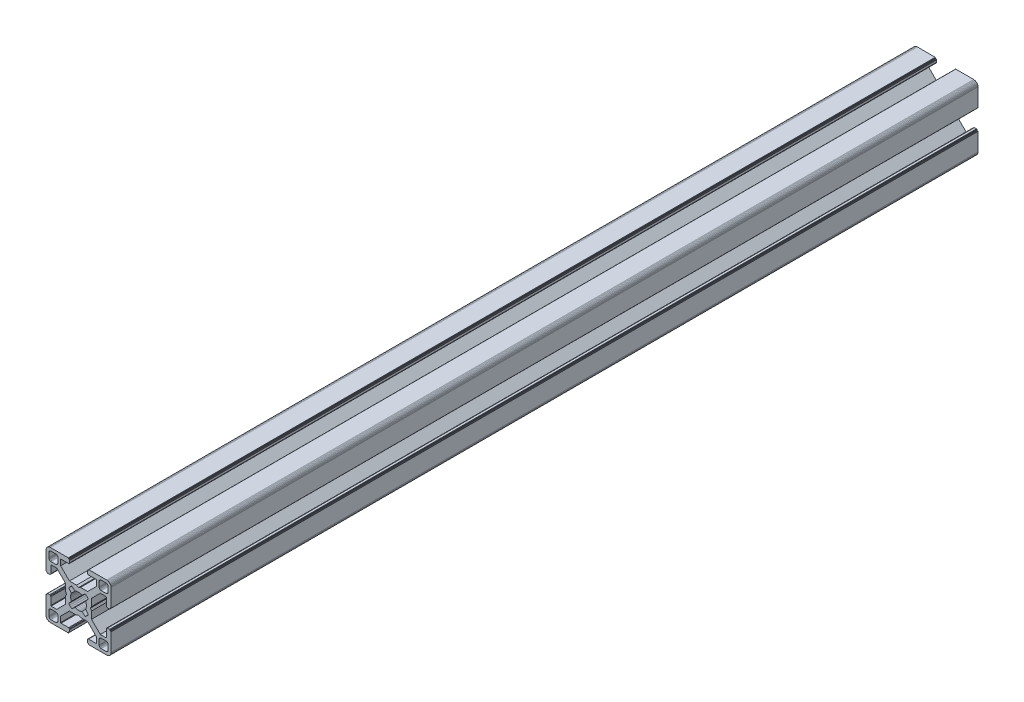
from build123d import *

# Parameters (mm, degrees)
BOSS_EXTRUDE1_DEPTH = 400


with BuildPart() as part:
    # Sketch1 → Boss-Extrude1 (new body)
    with BuildSketch(Plane.XY):
        Polygon((28.34729664, 29.969613999), (28.000000864, 29.999999329), (19.750000909, 29.999999329), (19.715268165, 29.996961355), (19.681595266, 29.987938702), (19.649999216, 29.973205179), (19.621443003, 29.953207821), (19.596790895, 29.928557575), (19.576793537, 29.899999499), (19.562061876, 29.868405312), (19.55303736, 29.834728688), (19.549999386, 29.799999669), (19.549999386, 29.699999839), (19.546961412, 29.665268958), (19.537936896, 29.631596059), (19.523203373, 29.599998146), (19.503207877, 29.571441934), (19.478557631, 29.546789825), (19.449999556, 29.526794329), (19.418403506, 29.512060806), (19.384728745, 29.503038153), (19.349999726, 29.500000179), (19.249999896, 29.500000179), (19.215267517, 29.496958527), (19.181592755, 29.487935874), (19.149996706, 29.47320235), (19.12143863, 29.453206855), (19.096788384, 29.428554746), (19.076791026, 29.399996671), (19.062057503, 29.368402484), (19.05303485, 29.334725859), (19.049996876, 29.299998703), (19.049996876, 28.39999837), (19.059110798, 28.29580945), (19.08618062, 28.194785165), (19.13038119, 28.099997016), (19.190369539, 28.014324653), (19.264324002, 27.94037019), (19.349996366, 27.88038184), (19.444784515, 27.836181271), (19.545806937, 27.809111449), (19.650010894, 27.799984574), (23.050010706, 27.799984574), (23.084741588, 27.7969466), (23.118414487, 27.787923946), (23.150012399, 27.773190423), (23.178568612, 27.753193065), (23.203220721, 27.728542819), (23.223218079, 27.699984744), (23.237949739, 27.668386831), (23.246974255, 27.634713932), (23.25001142, 27.59998608), (23.25001142, 25.049987618), (19.204474482, 20.999982084), (15.900007876, 20.999982084), (15.000008474, 20.48483404), (14.10000814, 20.999982084), (10.795543398, 20.999982084), (7.997342887, 23.801274731), (6.750011387, 25.049984589), (6.750011387, 27.599983051), (6.753049362, 27.634713932), (6.762072946, 27.668386831), (6.776805538, 27.699984744), (6.796801965, 27.728542819), (6.821454073, 27.753193065), (6.850011218, 27.773190423), (6.881607267, 27.787923946), (6.915282029, 27.7969466), (6.950011048, 27.799984574), (10.350011791, 27.799984574), (10.45420071, 27.809098497), (10.555223133, 27.836168318), (10.650011282, 27.880368888), (10.735683645, 27.940357238), (10.809638108, 28.014311701), (10.869626458, 28.099984064), (10.913827027, 28.194772213), (10.940895918, 28.295796498), (10.950010772, 28.399985417), (10.950010772, 29.299985751), (10.946974575, 29.334739239), (10.93795065, 29.368415522), (10.923215933, 29.400009153), (10.903218427, 29.428566473), (10.878566319, 29.45321765), (10.849999264, 29.473204166), (10.818403214, 29.487937689), (10.784728453, 29.496960342), (10.749999434, 29.500000179), (10.649999604, 29.500000179), (10.615270585, 29.503038153), (10.581595823, 29.512060806), (10.549999774, 29.526794329), (10.521441698, 29.546789825), (10.496791452, 29.571441934), (10.476795025, 29.599998146), (10.462061502, 29.631596059), (10.453037918, 29.665268958), (10.449999943, 29.699999839), (10.449999943, 29.799999669), (10.446961969, 29.834728688), (10.437938385, 29.868405312), (10.423205793, 29.899999499), (10.403208435, 29.928557575), (10.378557257, 29.953207821), (10.350000113, 29.973205179), (10.318404064, 29.987938702), (10.284729302, 29.996961355), (10.250000283, 29.999999329), (1.999999397, 29.999999329), (1.652702689, 29.969613999), (1.315958682, 29.879383743), (0.999999233, 29.732050374), (0.714424066, 29.532089829), (0.467910431, 29.285576195), (0.267948955, 28.999999166), (0.120614655, 28.684040532), (0.030384399, 28.34729664), (0, 28.000000864), (0, 19.750000909), (0.003037974, 19.715268165), (0.012061559, 19.681595266), (0.026795082, 19.649999216), (0.046790577, 19.621441141), (0.071442686, 19.596789032), (0.09999983, 19.576793537), (0.13159588, 19.562060013), (0.165270641, 19.55303736), (0.19999966, 19.549999386), (0.299999461, 19.549999386), (0.334728509, 19.546959549), (0.368403242, 19.537936896), (0.399999321, 19.523203373), (0.428556465, 19.503207877), (0.453208573, 19.478555769), (0.473204069, 19.449997693), (0.487937592, 19.418403506), (0.496961176, 19.384728745), (0.499999151, 19.349999726), (0.499999151, 19.249998033), (0.503038056, 19.215269014), (0.512060709, 19.181594253), (0.526794232, 19.150000066), (0.546790194, 19.121441524), (0.571441837, 19.096789882), (0.60000029, 19.076794925), (0.631595686, 19.062061999), (0.665270619, 19.053039982), (0.700000626, 19.050000801), (1.60000096, 19.050000801), (1.704189879, 19.059116587), (1.805213233, 19.086186409), (1.90000045, 19.130385115), (1.985673745, 19.190375328), (2.059627277, 19.264327928), (2.119616325, 19.350002154), (2.163816196, 19.444788441), (2.190886018, 19.545812726), (2.200000872, 19.650001645), (2.200000872, 23.050001457), (2.203039777, 23.084732338), (2.212062431, 23.118405237), (2.226795954, 23.15000315), (2.246792381, 23.178559362), (2.271443558, 23.203211471), (2.300000702, 23.223206967), (2.331596752, 23.23794049), (2.365271513, 23.246965006), (2.400001464, 23.250001117), (4.950000857, 23.250001117), (7.997332093, 20.202670812), (8.995535423, 19.204467788), (8.995535423, 15.900001182), (9.515148227, 15.00000178), (8.995535423, 14.100002378), (8.995535423, 10.795536704), (4.950000857, 6.750002138), (2.400001464, 6.750002138), (2.365271513, 6.753040112), (2.331596752, 6.762063697), (2.300000702, 6.77679722), (2.271443558, 6.796793647), (2.246792381, 6.821444824), (2.226795954, 6.850001968), (2.212062431, 6.881598018), (2.203039777, 6.915272779), (2.200000872, 6.950002729), (2.200000872, 10.350002542), (2.190896812, 10.454174265), (2.16382699, 10.555197618), (2.119627119, 10.649984836), (2.059638071, 10.735658131), (1.985684539, 10.809611663), (1.900011244, 10.869600944), (1.805224027, 10.913800582), (1.704200673, 10.940870404), (1.600011754, 10.949986189), (0.70001142, 10.949986189), (0.665281355, 10.946948596), (0.631606253, 10.937926283), (0.600010578, 10.923193954), (0.571451747, 10.903199537), (0.546799638, 10.87854836), (0.526794232, 10.850000195), (0.512060709, 10.818404146), (0.503038056, 10.784730315), (0.499999151, 10.750000365), (0.499999151, 10.650000535), (0.496961176, 10.615270585), (0.487937592, 10.581596754), (0.473204069, 10.550000705), (0.453208573, 10.521443561), (0.428556465, 10.496791452), (0.399999321, 10.476795956), (0.368403242, 10.462062433), (0.334728509, 10.453038849), (0.299999461, 10.449999943), (0.19999966, 10.449999943), (0.165270641, 10.446961969), (0.13159588, 10.437939316), (0.09999983, 10.423205793), (0.071442686, 10.403209366), (0.046790577, 10.378558189), (0.026795082, 10.350000113), (0.012061559, 10.318404064), (0.003037974, 10.284729302), (0, 10.250000283), (0, 1.999999397), (0.030384399, 1.652702689), (0.120614655, 1.315958682), (0.267948955, 0.999999233), (0.467910431, 0.714424066), (0.714424066, 0.467910431), (0.999999233, 0.267948955), (1.315958682, 0.120614655), (1.652702689, 0.030384399), (1.999999397, 0), (10.250000283, 0), (10.284729302, 0.003037974), (10.318404064, 0.012061559), (10.350000113, 0.026795082), (10.378557257, 0.046790577), (10.403208435, 0.071442686), (10.423205793, 0.09999983), (10.437938385, 0.13159588), (10.446961969, 0.165270641), (10.449999943, 0.19999966), (10.449999943, 0.300000422), (10.453037918, 0.334729441), (10.462061502, 0.368404202), (10.476795025, 0.400000252), (10.496791452, 0.428557396), (10.521441698, 0.453208573), (10.549999774, 0.473205), (10.581595823, 0.487938523), (10.615270585, 0.496961176), (10.649999604, 0.500000082), (10.749999434, 0.500000082), (10.784728453, 0.503038056), (10.818403214, 0.512060709), (10.849999264, 0.526794232), (10.878547894, 0.546800104), (10.903198606, 0.571451747), (10.923194493, 0.6000102), (10.93792742, 0.631606528), (10.946949437, 0.66528146), (10.950010772, 0.699984975), (10.950010772, 1.599985308), (10.940895918, 1.704174228), (10.913827027, 1.805197581), (10.869626458, 1.89998573), (10.809638108, 1.985658094), (10.735683645, 2.059612557), (10.650011282, 2.119600674), (10.555223133, 2.163801476), (10.45420071, 2.190870367), (10.350011791, 2.199985221), (6.950011048, 2.199985221), (6.915282029, 2.203024126), (6.881607267, 2.212046779), (6.850011218, 2.226780302), (6.821454073, 2.246776729), (6.796801965, 2.271427907), (6.776805538, 2.299985982), (6.762072946, 2.331582032), (6.753049362, 2.365256793), (6.750011387, 2.399985812), (6.750011387, 4.949985206), (9.787457566, 7.990785077), (10.795545277, 8.999985833), (14.100010019, 8.999985833), (15.000010353, 9.515133877), (15.900009756, 8.999985833), (19.204476361, 8.999985833), (20.21256413, 7.990786065), (23.25001142, 4.949988235), (23.25001142, 2.399988841), (23.246974255, 2.365256793), (23.237949739, 2.331582032), (23.223218079, 2.299985982), (23.203220721, 2.271427907), (23.178568612, 2.246776729), (23.150012399, 2.226780302), (23.118414487, 2.212046779), (23.084741588, 2.203024126), (23.050010706, 2.199985221), (19.650010894, 2.199985221), (19.545806937, 2.190883319), (19.444784515, 2.163814428), (19.349996366, 2.119613626), (19.264324002, 2.059625509), (19.190369539, 1.985671046), (19.13038119, 1.899998682), (19.08618062, 1.805210533), (19.059110798, 1.70418718), (19.049996876, 1.599998261), (19.049996876, 0.699997927), (19.053035506, 0.665268966), (19.062058795, 0.631594374), (19.076792915, 0.599998603), (19.096790813, 0.571440905), (19.121441524, 0.546790194), (19.149999978, 0.526794306), (19.181596306, 0.51206138), (19.215271238, 0.503039363), (19.249999896, 0.500000082), (19.349999726, 0.500000082), (19.384728745, 0.496961176), (19.418403506, 0.487938523), (19.449999556, 0.473205), (19.478557631, 0.453208573), (19.503207877, 0.428557396), (19.523203373, 0.400000252), (19.537936896, 0.368404202), (19.546961412, 0.334729441), (19.549999386, 0.300000422), (19.549999386, 0.19999966), (19.55303736, 0.165270641), (19.562061876, 0.13159588), (19.576793537, 0.09999983), (19.596789964, 0.071441755), (19.621442072, 0.046789646), (19.649998285, 0.02679415), (19.681594335, 0.012060627), (19.715267234, 0.003037043), (19.750000909, 0), (28.000000864, 0), (28.34729664, 0.030384399), (28.684040532, 0.120614655), (28.999999166, 0.267948955), (29.285576195, 0.467910431), (29.532089829, 0.714424066), (29.732050374, 0.999999233), (29.879383743, 1.315958682), (29.969613999, 1.652702689), (29.999999329, 1.999999397), (29.999999329, 10.250000283), (29.996974806, 10.284715361), (29.987951516, 10.318389952), (29.973217396, 10.349985723), (29.953219499, 10.378543421), (29.928568787, 10.403194133), (29.899999499, 10.423205793), (29.868405312, 10.437939316), (29.834728688, 10.446961969), (29.799999669, 10.449999943), (29.699999839, 10.449999943), (29.664909937, 10.453400043), (29.631233313, 10.462423628), (29.599637263, 10.477157151), (29.57108105, 10.497152646), (29.546427079, 10.521804755), (29.526433446, 10.550361899), (29.511699923, 10.581957949), (29.502675407, 10.615631779), (29.499637433, 10.650361729), (29.499637433, 10.750361559), (29.49697202, 10.784715548), (29.487949367, 10.818389378), (29.473215844, 10.849985428), (29.453220348, 10.878542572), (29.428568239, 10.90319468), (29.400010164, 10.923190176), (29.368415977, 10.937923699), (29.334741215, 10.946947284), (29.300012197, 10.949986189), (28.400011863, 10.949986189), (28.29581215, 10.9408876), (28.194787865, 10.913817778), (28.099999716, 10.86961814), (28.014327352, 10.809628859), (27.940374752, 10.735675327), (27.880384539, 10.650002032), (27.836185833, 10.555214814), (27.809114148, 10.454191461), (27.800000225, 10.350002542), (27.800000225, 6.950002729), (27.796962251, 6.915272779), (27.787939598, 6.881598018), (27.773206075, 6.850001968), (27.753208716, 6.821444824), (27.728558471, 6.796793647), (27.700000395, 6.77679722), (27.668404345, 6.762063697), (27.634729584, 6.753040112), (27.599998702, 6.750002138), (25.05000024, 6.750002138), (23.809199132, 7.99080223), (21.004464477, 10.795534588), (21.004464477, 14.100000262), (20.484851673, 14.999999665), (21.004464477, 15.899999067), (21.004464477, 19.204465672), (25.05000024, 23.250001117), (27.599998702, 23.250001117), (27.634729584, 23.246965006), (27.668404345, 23.23794049), (27.700000395, 23.223206967), (27.728558471, 23.203211471), (27.753208716, 23.178559362), (27.773206075, 23.15000315), (27.787939598, 23.118405237), (27.796962251, 23.084732338), (27.800000225, 23.050001457), (27.800000225, 19.650001645), (27.809114148, 19.545812726), (27.836185833, 19.444788441), (27.880384539, 19.350002154), (27.940370508, 19.264323684), (28.014323108, 19.190371084), (28.099995472, 19.130380872), (28.194783621, 19.086182165), (28.295807906, 19.059112343), (28.400001069, 19.050000801), (29.300001402, 19.050000801), (29.334730421, 19.053040638), (29.368405183, 19.062063291), (29.39999937, 19.076796814), (29.42819671, 19.097149726), (29.452848353, 19.1218023), (29.472843309, 19.150360754), (29.487576235, 19.181955219), (29.496598252, 19.215630151), (29.499637433, 19.250359227), (29.499637433, 19.35036092), (29.502675407, 19.385089939), (29.511699923, 19.4187647), (29.526433446, 19.450358887), (29.546427079, 19.478916963), (29.57108105, 19.503569071), (29.599637263, 19.523564567), (29.631233313, 19.53829809), (29.664909937, 19.547320743), (29.699999839, 19.549999386), (29.799999669, 19.549999386), (29.834728688, 19.55303736), (29.868405312, 19.562060013), (29.899999499, 19.576793537), (29.928557575, 19.596789032), (29.953207821, 19.621441141), (29.973205179, 19.649999216), (29.987938702, 19.681595266), (29.996961355, 19.715268165), (29.999999329, 19.750000909), (29.999999329, 28.000000864), (29.969613999, 28.34729664), (29.879383743, 28.684040532), (29.732050374, 28.999999166), (29.532089829, 29.285576195), (29.285576195, 29.532089829), (28.999999166, 29.732050374), (28.684040532, 29.879383743), align=None)
        Polygon((1.299998723, 25.499999523), (1.299998723, 27.699999511), (1.312309876, 27.856435627), (1.348942518, 28.009016067), (1.408992335, 28.153989464), (1.490981318, 28.287785128), (1.592892222, 28.407108039), (1.71221327, 28.50901708), (1.846008119, 28.591006994), (1.9909814, 28.651056811), (2.143563703, 28.687689453), (2.299998887, 28.699999675), (4.499998875, 28.699999675), (4.656434059, 28.687689453), (4.809016362, 28.651056811), (4.953989759, 28.591006994), (5.087784491, 28.50901708), (5.207106471, 28.407108039), (5.309016444, 28.287785128), (5.391005427, 28.153989464), (5.451056175, 28.009016067), (5.487687886, 27.856435627), (5.499999039, 27.699999511), (5.499999039, 25.499999523), (5.487687886, 25.34356527), (5.451056175, 25.190982968), (5.391005427, 25.04600957), (5.309016444, 24.912213907), (5.207106471, 24.792892858), (5.087784491, 24.690981954), (4.953989759, 24.60899204), (4.809016362, 24.548944086), (4.656434059, 24.512309581), (4.499998875, 24.499999359), (2.299998887, 24.499999359), (2.143563703, 24.512309581), (1.9909814, 24.548944086), (1.846008119, 24.60899204), (1.71221327, 24.690981954), (1.592892222, 24.792892858), (1.490981318, 24.912213907), (1.408992335, 25.04600957), (1.348942518, 25.190982968), (1.312309876, 25.34356527), align=None, mode=Mode.SUBTRACT)
        Polygon((25.34356527, 28.687689453), (25.499999523, 28.699999675), (27.699999511, 28.699999675), (27.856435627, 28.687689453), (28.009017929, 28.651056811), (28.153991327, 28.591006994), (28.28778699, 28.50901708), (28.407108039, 28.407108039), (28.50901708, 28.287785128), (28.591006994, 28.153989464), (28.651056811, 28.009016067), (28.687689453, 27.856435627), (28.700001538, 27.699999511), (28.700001538, 25.499999523), (28.687689453, 25.34356527), (28.651056811, 25.190982968), (28.591006994, 25.04600957), (28.50901708, 24.912213907), (28.407108039, 24.792892858), (28.28778699, 24.690981954), (28.153991327, 24.60899204), (28.009017929, 24.548944086), (27.856435627, 24.512309581), (27.699999511, 24.499999359), (25.499999523, 24.499999359), (25.34356527, 24.512309581), (25.190982968, 24.548944086), (25.04600957, 24.60899204), (24.912215769, 24.690981954), (24.792892858, 24.792892858), (24.690981954, 24.912213907), (24.608993903, 25.04600957), (24.548944086, 25.190982968), (24.512311444, 25.34356527), (24.500001222, 25.499999523), (24.500001222, 27.699999511), (24.512311444, 27.856435627), (24.548944086, 28.009016067), (24.608993903, 28.153989464), (24.690981954, 28.287785128), (24.792892858, 28.407108039), (24.912215769, 28.50901708), (25.04600957, 28.591006994), (25.190982968, 28.651056811), align=None, mode=Mode.SUBTRACT)
        Polygon((14.999999665, 18.649999052), (15.550030395, 18.608318642), (16.087498516, 18.484227359), (16.600128263, 18.280562013), (18.13592948, 19.518401474), (18.644984812, 19.11874488), (19.103571773, 18.662061542), (19.505336881, 18.154669553), (18.280562013, 16.600130126), (18.484227359, 16.087498516), (18.608318642, 15.550030395), (18.649999052, 14.999999665), (18.608318642, 14.449968934), (18.484227359, 13.912500814), (18.280562013, 13.399870135), (19.505336881, 11.845329776), (19.103571773, 11.337937787), (18.644984812, 10.881252587), (18.13592948, 10.481598787), (16.600128263, 11.719437316), (16.087498516, 11.515771039), (15.550030395, 11.391680688), (14.999999665, 11.349999346), (14.449968934, 11.391680688), (13.912500814, 11.515771039), (13.399870135, 11.719437316), (11.864069849, 10.481598787), (11.355013587, 10.881252587), (10.896427557, 11.337937787), (10.494662449, 11.845329776), (11.719438247, 13.399870135), (11.515771039, 13.912500814), (11.391680688, 14.449968934), (11.349999346, 14.999999665), (11.391680688, 15.550030395), (11.515771039, 16.087498516), (11.719438247, 16.600130126), (10.494662449, 18.154669553), (10.896427557, 18.662061542), (11.355013587, 19.11874488), (11.864069849, 19.518401474), (13.399870135, 18.280562013), (13.912500814, 18.484227359), (14.449968934, 18.608318642), align=None, mode=Mode.SUBTRACT)
        Polygon((4.499998875, 1.299999771), (2.299998887, 1.299999771), (2.143563703, 1.312310807), (1.9909814, 1.348942518), (1.846008119, 1.408992335), (1.71221327, 1.490982249), (1.592892222, 1.592892222), (1.490981318, 1.712214202), (1.408992335, 1.846008934), (1.348942518, 1.990982331), (1.312309876, 2.143564634), (1.299998723, 2.299998887), (1.299998723, 4.499999806), (1.312309876, 4.656434059), (1.348942518, 4.809017293), (1.408992335, 4.95399069), (1.490981318, 5.087785423), (1.592892222, 5.207106471), (1.71221327, 5.309017375), (1.846008119, 5.391006358), (1.9909814, 5.451056175), (2.143563703, 5.487688817), (2.299998887, 5.49999997), (4.499998875, 5.49999997), (4.656434059, 5.487688817), (4.809016362, 5.451056175), (4.953989759, 5.391006358), (5.087784491, 5.309017375), (5.207106471, 5.207106471), (5.309016444, 5.087785423), (5.391005427, 4.95399069), (5.451056175, 4.809017293), (5.487687886, 4.656434059), (5.499999039, 4.499999806), (5.499999039, 2.299998887), (5.487687886, 2.143564634), (5.451056175, 1.990982331), (5.391005427, 1.846008934), (5.309016444, 1.712214202), (5.207106471, 1.592892222), (5.087784491, 1.490982249), (4.953989759, 1.408992335), (4.809016362, 1.348942518), (4.656434059, 1.312310807), align=None, mode=Mode.SUBTRACT)
        Polygon((27.699999511, 1.299999771), (25.499999523, 1.299999771), (25.34356527, 1.312310807), (25.190982968, 1.348942518), (25.04600957, 1.408992335), (24.912215769, 1.490982249), (24.792892858, 1.592892222), (24.690981954, 1.712214202), (24.608993903, 1.846008934), (24.548944086, 1.990982331), (24.512311444, 2.143564634), (24.500001222, 2.299998887), (24.500001222, 4.499999806), (24.512311444, 4.656434059), (24.548944086, 4.809017293), (24.608993903, 4.95399069), (24.690981954, 5.087785423), (24.792892858, 5.207106471), (24.912215769, 5.309017375), (25.04600957, 5.391006358), (25.190982968, 5.451056175), (25.34356527, 5.487688817), (25.499999523, 5.49999997), (27.699999511, 5.49999997), (27.856435627, 5.487688817), (28.009017929, 5.451056175), (28.153991327, 5.391006358), (28.28778699, 5.309017375), (28.407108039, 5.207106471), (28.50901708, 5.087785423), (28.591006994, 4.95399069), (28.651056811, 4.809017293), (28.687689453, 4.656434059), (28.700001538, 4.499999806), (28.700001538, 2.299998887), (28.687689453, 2.143564634), (28.651056811, 1.990982331), (28.591006994, 1.846008934), (28.50901708, 1.712214202), (28.407108039, 1.592892222), (28.28778699, 1.490982249), (28.153991327, 1.408992335), (28.009017929, 1.348942518), (27.856435627, 1.312310807), align=None, mode=Mode.SUBTRACT)
    extrude(amount=-BOSS_EXTRUDE1_DEPTH)


solid = part.part
